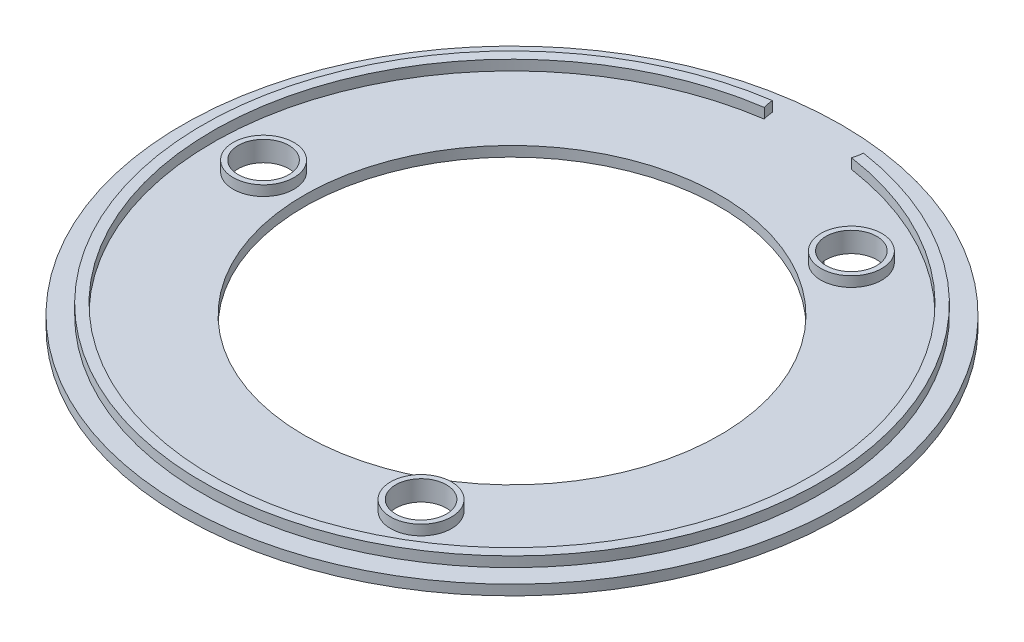
from build123d import *

# Parameters (mm, degrees)
CROQUIS1_R                 = 32.5
CROQUIS1_R_2               = 20.5
SALIENTE_EXTRUIR1_DEPTH    = 2
CORTAR_EXTRUIR1_START      = -1
CROQUIS2_R                 = 32.5
CROQUIS2_R_2               = 20.5
CORTAR_EXTRUIR1_DEPTH      = 1
CROQUIS3_R                 = 3
CROQUIS3_R_2               = 2.5
SALIENTE_EXTRUIR2_DEPTH    = 1
CORTAR_EXTRUIR2_DEPTH      = 29
CORTAR_EXTRUIR2_DEPTH_BACK = 25
CROQUIS6_R                 = 2.5
SALIENTE_EXTRUIR3_DEPTH    = 1


with BuildPart() as part:
    # Croquis1 → Saliente-Extruir1 (new body)
    with BuildSketch(Plane(origin=(0, 0, 0), x_dir=(1, 0, 0), z_dir=(0, 1, 0))):
        Circle(CROQUIS1_R)
        Circle(CROQUIS1_R_2, mode=Mode.SUBTRACT)
    extrude(amount=SALIENTE_EXTRUIR1_DEPTH)

    # Croquis2 → Cortar-Extruir1 (cut)
    with BuildSketch(Plane(origin=(0, 2, 0), x_dir=(1, 0, 0), z_dir=(0, 1, 0)).offset(CORTAR_EXTRUIR1_START)):
        Circle(CROQUIS2_R)
        with BuildLine():
            ThreePointArc((4.487738603, 30.168032787), (0, -30.5), (-4.487738603, 30.168032787))
            ThreePointArc((-4.487738603, 30.168032787), (-4.42299753, 29.671089358), (-4.303401638, 29.18442623))
            ThreePointArc((-4.303401638, 29.18442623), (0, -29.5), (4.303401638, 29.18442623))
            ThreePointArc((4.303401638, 29.18442623), (4.42299753, 29.671089358), (4.487738603, 30.168032787))
        make_face(mode=Mode.SUBTRACT)
        Circle(CROQUIS2_R_2, mode=Mode.SUBTRACT)
    extrude(amount=CORTAR_EXTRUIR1_DEPTH, mode=Mode.SUBTRACT)

    # Croquis3 → Saliente-Extruir2 (add)
    # profile 1 of 3: a face of its own
    with BuildSketch(Plane(origin=(0, 1, 0), x_dir=(1, 0, 0), z_dir=(0, 1, 0))):
        with Locations((-24.5, 0)):
            Circle(CROQUIS3_R)
        with Locations((-24.5, 0)):
            Circle(CROQUIS3_R_2, mode=Mode.SUBTRACT)
    # profile 2 of 3: a face of its own
    with BuildSketch(Plane(origin=(0, 1, 0), x_dir=(1, 0, 0), z_dir=(0, 1, 0))):
        with Locations((12.25, 21.217622393)):
            Circle(CROQUIS3_R)
        with Locations((12.25, 21.217622393)):
            Circle(CROQUIS3_R_2, mode=Mode.SUBTRACT)
    # profile 3 of 3: a face of its own
    with BuildSketch(Plane(origin=(0, 1, 0), x_dir=(1, 0, 0), z_dir=(0, 1, 0))):
        with Locations((12.25, -21.217622393)):
            Circle(CROQUIS3_R)
        with Locations((12.25, -21.217622393)):
            Circle(CROQUIS3_R_2, mode=Mode.SUBTRACT)
    extrude(amount=SALIENTE_EXTRUIR2_DEPTH)

    # Croquis6 → Cortar-Extruir2 (cut, two sides: drawn at the far end of the back side and taken through both)
    with BuildSketch(Plane(origin=(0, 1, 0), x_dir=(1, 0, 0), z_dir=(0, 1, 0)).offset(-CORTAR_EXTRUIR2_DEPTH_BACK)):
        with Locations((-24.5, 0)):
            Circle(CROQUIS6_R)
        with Locations((12.25, -21.217622393)):
            Circle(CROQUIS6_R)
        with Locations((12.25, 21.217622393)):
            Circle(CROQUIS6_R)
    extrude(amount=CORTAR_EXTRUIR2_DEPTH + CORTAR_EXTRUIR2_DEPTH_BACK, mode=Mode.SUBTRACT)

    # Croquis7 → Saliente-Extruir3 (add)
    with BuildSketch(Plane.XZ):
        with BuildLine():
            ThreePointArc((9.061477105, 21.682703537), (-11.747329093, 20.353138804), (-23.307724042, 3))
            Line((-23.307724042, 3), (-22.803508502, 3))
            ThreePointArc((-22.803508502, 3), (-11.469500389, 19.936162139), (8.86867972, 21.221369419))
            Line((8.86867972, 21.221369419), (9.061477105, 21.682703537))
        make_face()
        with BuildLine():
            Line((-22.803508502, -3), (-23.307724042, -3))
            ThreePointArc((-23.307724042, -3), (-11.747329093, -20.353138804), (9.061477105, -21.682703537))
            Line((9.061477105, -21.682703537), (8.86867972, -21.221369419))
            ThreePointArc((8.86867972, -21.221369419), (-11.469500389, -19.936162139), (-22.803508502, -3))
        make_face()
        with BuildLine():
            ThreePointArc((14.36118164, -18.601248934), (23.4998899, 0.071935181), (14.247033533, 18.688821137))
            Line((14.247033533, 18.688821137), (13.94390516, 18.291186645))
            ThreePointArc((13.94390516, 18.291186645), (22.999892243, 0.070404645), (14.055624583, -18.20547768))
            Line((14.055624583, -18.20547768), (14.36118164, -18.601248934))
        make_face()
    extrude(amount=SALIENTE_EXTRUIR3_DEPTH)


solid = part.part
